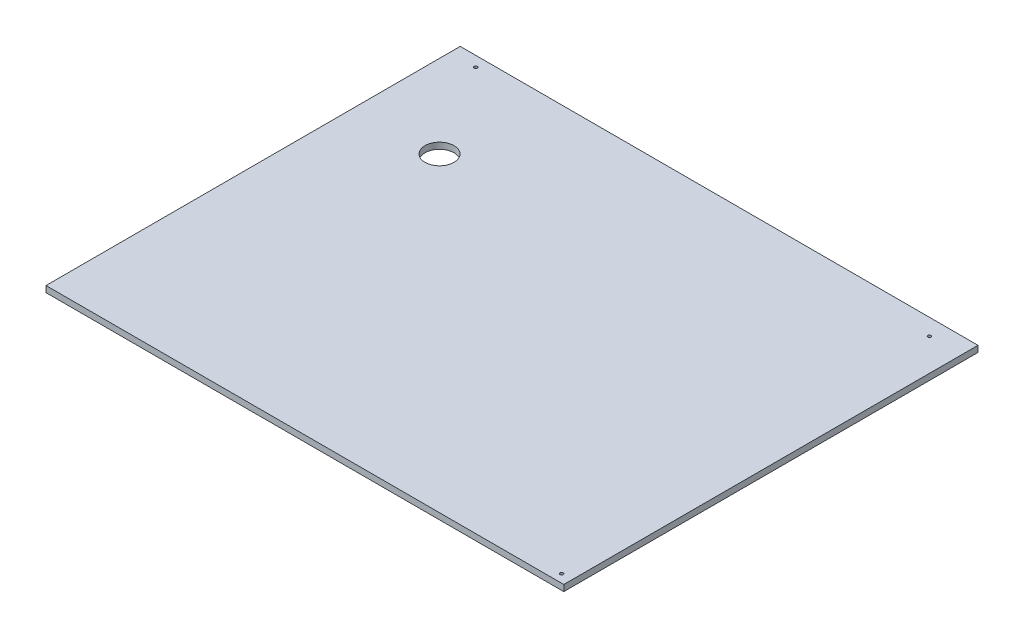
from build123d import *

# Parameters (mm, degrees)
SKETCH1_W           = 500
SKETCH1_H           = 400
SKETCH1_R           = 1.525
SKETCH1_R_2         = 14
SKETCH1_R_3         = 1.5
BOSS_EXTRUDE1_DEPTH = 6


with BuildPart() as part:
    # Sketch1 → Boss-Extrude1 (new body)
    with BuildSketch(Plane(origin=(0, 0, 0), x_dir=(1, 0, 0), z_dir=(0, 1, 0))):
        with Locations((250, -200)):
            Rectangle(SKETCH1_W, SKETCH1_H)
        with Locations((25, -10)):
            Circle(SKETCH1_R, mode=Mode.SUBTRACT)
        with Locations((80, -100)):
            Circle(SKETCH1_R_2, mode=Mode.SUBTRACT)
        with Locations((490, -392)):
            Circle(SKETCH1_R_3, mode=Mode.SUBTRACT)
        with Locations((469, -16)):
            Circle(SKETCH1_R_3, mode=Mode.SUBTRACT)
    extrude(amount=BOSS_EXTRUDE1_DEPTH)


solid = part.part
